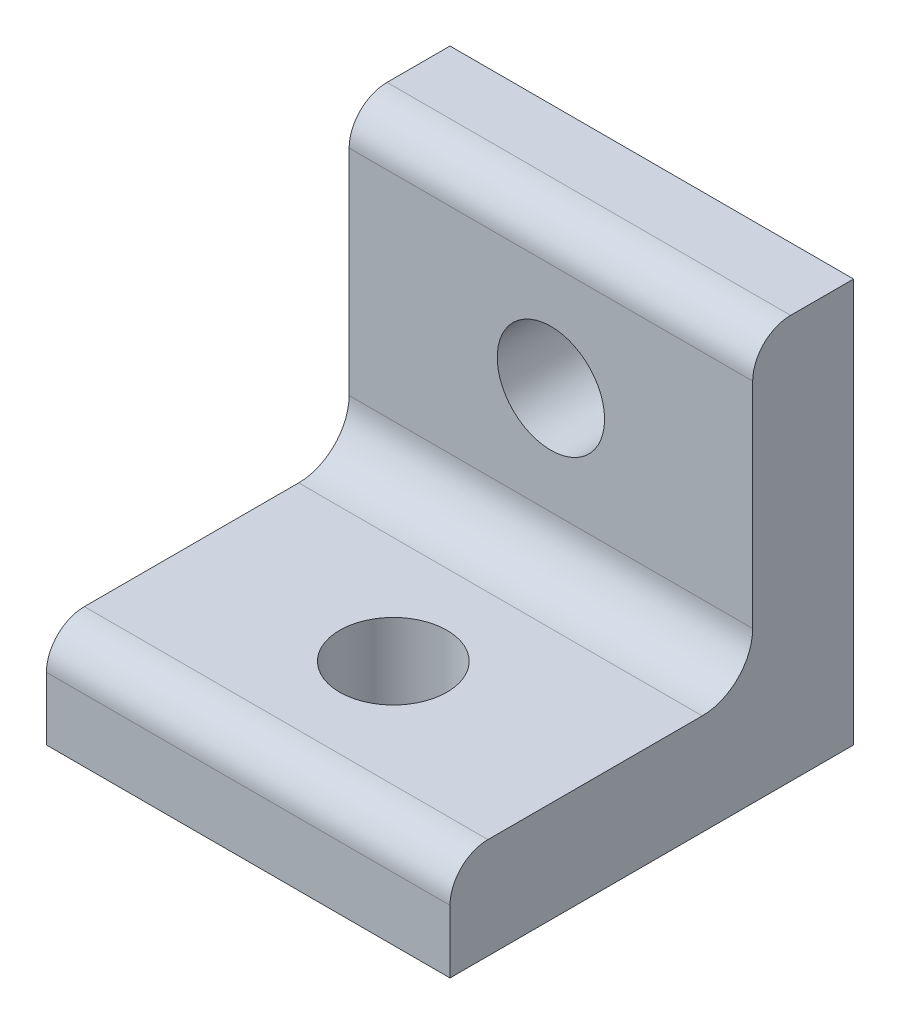
from build123d import *

# Parameters (mm, degrees)
SKETCH1_W           = 25.4
SKETCH1_H           = 25.4
BOSS_EXTRUDE1_DEPTH = 6.35
SKETCH2_W           = 25.4
SKETCH2_H           = 25.4
BOSS_EXTRUDE2_DEPTH = 6.35
FILLET1_R           = 3.175
FILLET2_R           = 2.3876
SKETCH3_R           = 3.3782
CUT_EXTRUDE1_DEPTH  = 7.35
SKETCH4_R           = 3.3782
CUT_EXTRUDE2_DEPTH  = 7.35


with BuildPart() as part:
    # Sketch1 → Boss-Extrude1 (new body)
    with BuildSketch(Plane(origin=(0, 0, 0), x_dir=(1, 0, 0), z_dir=(0, 1, 0))):
        with Locations((12.7, 12.7)):
            Rectangle(SKETCH1_W, SKETCH1_H)
    extrude(amount=BOSS_EXTRUDE1_DEPTH)

    # Sketch2 → Boss-Extrude2 (add)
    with BuildSketch(Plane(origin=(0, 0, -25.4), x_dir=(-1, 0, 0), z_dir=(0, 0, -1))):
        with Locations((-12.7, 12.7)):
            Rectangle(SKETCH2_W, SKETCH2_H)
    extrude(amount=-BOSS_EXTRUDE2_DEPTH)

    # Fillet1
    fillet1_edges = [part.edges().sort_by_distance(p)[0] for p in [
        (12.7, 6.35, -19.05),
    ]]
    fillet(fillet1_edges, radius=FILLET1_R)

    # Fillet2
    fillet2_edges = [part.edges().sort_by_distance(p)[0] for p in [
        (12.7, 25.4, -19.05),
        (12.7, 6.35, 0),
    ]]
    fillet(fillet2_edges, radius=FILLET2_R)

    # Sketch3 → Cut-Extrude1 (cut, through all)
    with BuildSketch(Plane(origin=(0, 6.35, 0), x_dir=(1, 0, 0), z_dir=(0, 1, 0))):
        with Locations((12.7, 9.1313)):
            Circle(SKETCH3_R)
        with Locations((29.80436, 9.1313)):
            Circle(SKETCH3_R)
        with Locations((46.39564, 9.1313)):
            Circle(SKETCH3_R)
        with Locations((33.500058156, 19.57038717)):
            Circle(SKETCH3_R)
    extrude(amount=-CUT_EXTRUDE1_DEPTH, mode=Mode.SUBTRACT)

    # Sketch4 → Cut-Extrude2 (cut, through all)
    with BuildSketch(Plane.XY.offset(-19.05)):
        with Locations((-37.07384, 16.2687)):
            Circle(SKETCH4_R)
        with Locations((-20.48256, 16.2687)):
            Circle(SKETCH4_R)
        with Locations((-3.89128, 16.2687)):
            Circle(SKETCH4_R)
        with Locations((12.7, 16.2687)):
            Circle(SKETCH4_R)
    extrude(amount=-CUT_EXTRUDE2_DEPTH, mode=Mode.SUBTRACT)


solid = part.part
